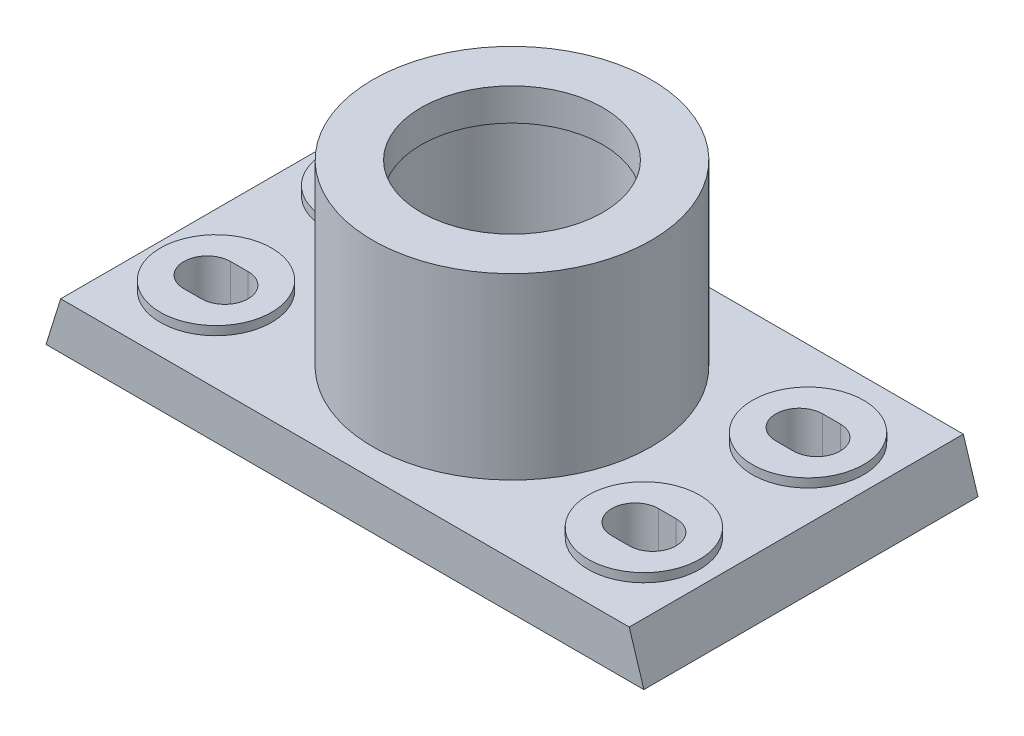
from build123d import *

# Parameters (mm, degrees)
BOSS_EXTRUDE1_DEPTH = 114
SKETCH3_W           = 82.5
SKETCH3_H           = 94
CUT_EXTRUDE1_DEPTH  = 3
CUT_EXTRUDE2_DEPTH  = 17
SKETCH5_R           = 19
BOSS_EXTRUDE2_DEPTH = 3
SKETCH6_R           = 47.5
SKETCH6_R_2         = 31
BOSS_EXTRUDE4_DEPTH = 61
SKETCH8_W           = 3
SKETCH8_H           = 35.544994967
SKETCH9_R           = 1.5
CUT_EXTRUDE3_DEPTH  = 22


with BuildPart() as part:
    # Sketch2 → Boss-Extrude1 (new body)
    with BuildSketch(Plane.XY):
        Polygon((-102, 0), (-97, 16), (97, 16), (102, 0), align=None)
    extrude(amount=-BOSS_EXTRUDE1_DEPTH)

    # Sketch3 → Cut-Extrude1 (cut)
    with BuildSketch(Plane.XZ):
        with Locations((-50.75, -57)):
            Rectangle(SKETCH3_W, SKETCH3_H)
        with Locations((50.75, -57)):
            Rectangle(SKETCH3_W, SKETCH3_H)
    extrude(amount=-CUT_EXTRUDE1_DEPTH, mode=Mode.SUBTRACT)

    # Sketch4 → Cut-Extrude2 (cut, through all)
    with BuildSketch(Plane(origin=(0, 16, 0), x_dir=(1, 0, 0), z_dir=(0, 1, 0))):
        with BuildLine():
            Line((-76, 77), (-70, 77))
            ThreePointArc((-70, 77), (-62, 85), (-70, 93))
            Line((-70, 93), (-76, 93))
            ThreePointArc((-76, 93), (-84, 85), (-76, 77))
        make_face()
        with BuildLine():
            ThreePointArc((70, 77), (62, 85), (70, 93))
            Line((70, 93), (76, 93))
            ThreePointArc((76, 93), (84, 85), (76, 77))
            Line((76, 77), (70, 77))
        make_face()
        with BuildLine():
            ThreePointArc((-70, 37), (-62, 29), (-70, 21))
            Line((-70, 21), (-76, 21))
            ThreePointArc((-76, 21), (-84, 29), (-76, 37))
            Line((-76, 37), (-70, 37))
        make_face()
        with BuildLine():
            Line((76, 37), (70, 37))
            ThreePointArc((70, 37), (62, 29), (70, 21))
            Line((70, 21), (76, 21))
            ThreePointArc((76, 21), (84, 29), (76, 37))
        make_face()
    extrude(amount=-CUT_EXTRUDE2_DEPTH, mode=Mode.SUBTRACT)

    # Sketch5 → Boss-Extrude2 (add)
    with BuildSketch(Plane(origin=(0, 16, 0), x_dir=(1, 0, 0), z_dir=(0, 1, 0))):
        with Locations(Location((-73, 85, 0), (0, 0, 180))):  # turned: the seam where the file's is
            Circle(SKETCH5_R)
        with BuildLine():
            ThreePointArc((-70, 93), (-62, 85), (-70, 77))
            Line((-70, 77), (-76, 77))
            ThreePointArc((-76, 77), (-84, 85), (-76, 93))
            Line((-76, 93), (-70, 93))
        make_face(mode=Mode.SUBTRACT)
        with Locations(Location((73, 85, 0), (0, 0, 180))):  # turned: the seam where the file's is
            Circle(SKETCH5_R)
        with BuildLine():
            ThreePointArc((76, 93), (84, 85), (76, 77))
            Line((76, 77), (70, 77))
            ThreePointArc((70, 77), (62, 85), (70, 93))
            Line((70, 93), (76, 93))
        make_face(mode=Mode.SUBTRACT)
        with Locations(Location((73, 29, 0), (0, 0, 180))):  # turned: the seam where the file's is
            Circle(SKETCH5_R)
        with BuildLine():
            ThreePointArc((70, 21), (62, 29), (70, 37))
            Line((70, 37), (76, 37))
            ThreePointArc((76, 37), (84, 29), (76, 21))
            Line((76, 21), (70, 21))
        make_face(mode=Mode.SUBTRACT)
        with Locations(Location((-73, 29, 0), (0, 0, 180))):  # turned: the seam where the file's is
            Circle(SKETCH5_R)
        with BuildLine():
            ThreePointArc((-76, 21), (-84, 29), (-76, 37))
            Line((-76, 37), (-70, 37))
            ThreePointArc((-70, 37), (-62, 29), (-70, 21))
            Line((-70, 21), (-76, 21))
        make_face(mode=Mode.SUBTRACT)
    extrude(amount=BOSS_EXTRUDE2_DEPTH)

    # Sketch6 → Boss-Extrude4 (add)
    with BuildSketch(Plane(origin=(0, 16, 0), x_dir=(1, 0, 0), z_dir=(0, 1, 0))):
        with Locations(Location((0, 57, 0), (0, 0, 180))):  # turned: the seam where the file's is
            Circle(SKETCH6_R)
        with Locations(Location((0, 57, 0), (0, 0, 180))):  # turned: the seam where the file's is
            Circle(SKETCH6_R_2, mode=Mode.SUBTRACT)
    extrude(amount=BOSS_EXTRUDE4_DEPTH)

    # Sketch8 → Cut-Revolve1 (revolve, cut)
    with BuildSketch(Plane.XY.offset(-57)):
        with Locations((-31, 48.227502517)):
            Rectangle(SKETCH8_W, SKETCH8_H)
    revolve(axis=Axis((0, 107.106199385, -57), (0, -1, 0)), mode=Mode.SUBTRACT)

    # Sketch9 → Cut-Extrude3 (cut)
    with BuildSketch(Plane(origin=(0, 16, 0), x_dir=(1, 0, 0), z_dir=(0, 1, 0))):
        with Locations(Location((-22, 57, 0), (0, 0, 180))):  # turned: the seam where the file's is
            Circle(SKETCH9_R)
    extrude(amount=-CUT_EXTRUDE3_DEPTH, mode=Mode.SUBTRACT)


solid = part.part
